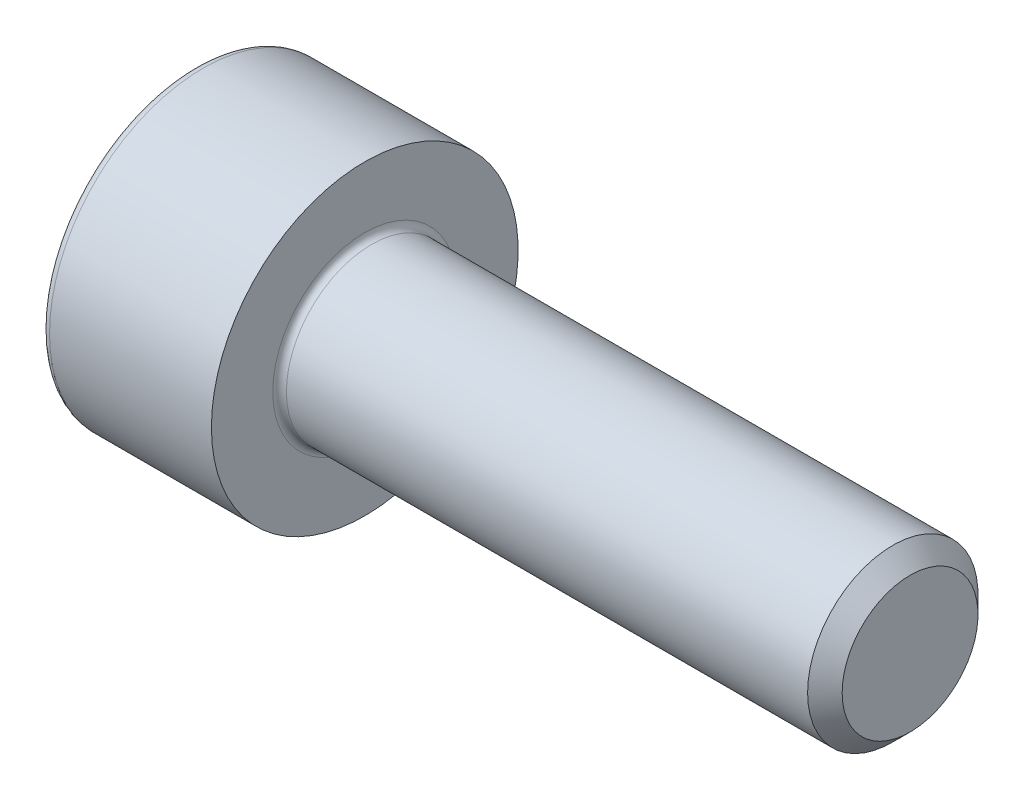
from build123d import *

# Parameters (mm, degrees)
FILLET1_R   = 0.1
FILLET2_R   = 0.125
HEX_2_DEPTH = 1.1


with BuildPart() as part:
    # BodySke → Base-Revolve (revolve)
    with BuildSketch(Plane.XY):
        Polygon((0, 0), (0, 2.25), (2.5, 2.25), (2.5, 1.25), (10.2465, 1.25), (10.5, 0.9965), (10.5, 0), align=None)
    revolve(axis=Axis((-31.75, 0, 0), (1, 0, 0)))

    # Fillet1
    fillet1_edges = [part.edges().sort_by_distance(p)[0] for p in [
        (2.5, -1.25, 0),
    ]]
    fillet(fillet1_edges, radius=FILLET1_R)

    # Fillet2
    fillet2_edges = [part.edges().sort_by_distance(p)[0] for p in [
        (0, -2.25, 0),
    ]]
    fillet(fillet2_edges, radius=FILLET2_R)

    # Sketch2 → Hex-PreBroach (revolve, cut)
    with BuildSketch(Plane.XY):
        Polygon((0, 1.0225), (1.1, 1.0225), (1.69034065, 0), (0, 0), align=None)
    revolve(axis=Axis((0, 0, 0), (1, 0, 0)), mode=Mode.SUBTRACT)

    # Sketch3 → Hex 2 (cut)
    with BuildSketch(Plane(origin=(0, 0, 0), x_dir=(0, 0.5, 0.866025404), z_dir=(-1, 0, 0))):
        Polygon((0.59034065, 1.0225), (-0.59034065, 1.0225), (-1.1806813, 0), (-0.59034065, -1.0225), (0.59034065, -1.0225), (1.1806813, 0), align=None)
    extrude(amount=-HEX_2_DEPTH, mode=Mode.SUBTRACT)


solid = part.part
